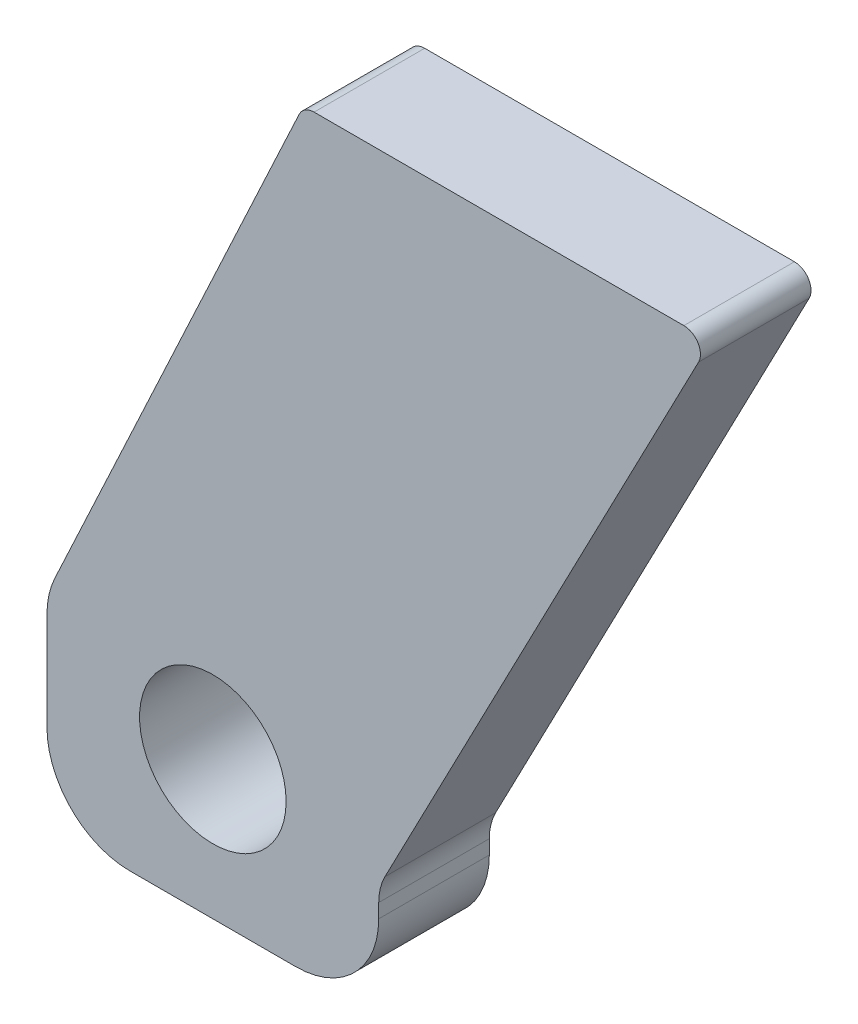
from build123d import *

# Parameters (mm, degrees)
SKETCH1_R          = 13.25
BASE_EXTRUDE_DEPTH = 20


with BuildPart() as part:
    # Sketch1 → Base-Extrude (new body)
    with BuildSketch(Plane.XY):
        with BuildLine():
            Line((30, -7.446984432), (30, -10))
            ThreePointArc((30, -10), (25.606601718, -20.606601718), (15, -25))
            Line((15, -25), (-15, -25))
            ThreePointArc((-15, -25), (-25.606601718, -20.606601718), (-30, -10))
            Line((-30, -10), (-30, 7.67458006))
            ThreePointArc((-30, 7.67458006), (-29.644440107, 10.921174269), (-28.594616806, 14.013853986))
            Line((-28.594616806, 14.013853986), (15.589899408, 108.767854785))
            ThreePointArc((15.589899408, 108.767854785), (16.696923944, 110.030174337), (18.308822769, 110.5))
            Line((18.308822769, 110.5), (85.181647346, 110.5))
            ThreePointArc((85.181647346, 110.5), (87.746382958, 109.056319774), (87.842679846, 106.11475416))
            Line((87.842679846, 106.11475416), (31.129891668, -2.8294983))
            ThreePointArc((31.129891668, -2.8294983), (30.286579302, -5.070125509), (30, -7.446984432))
        make_face()
        Circle(SKETCH1_R, mode=Mode.SUBTRACT)
    extrude(amount=BASE_EXTRUDE_DEPTH)


solid = part.part
